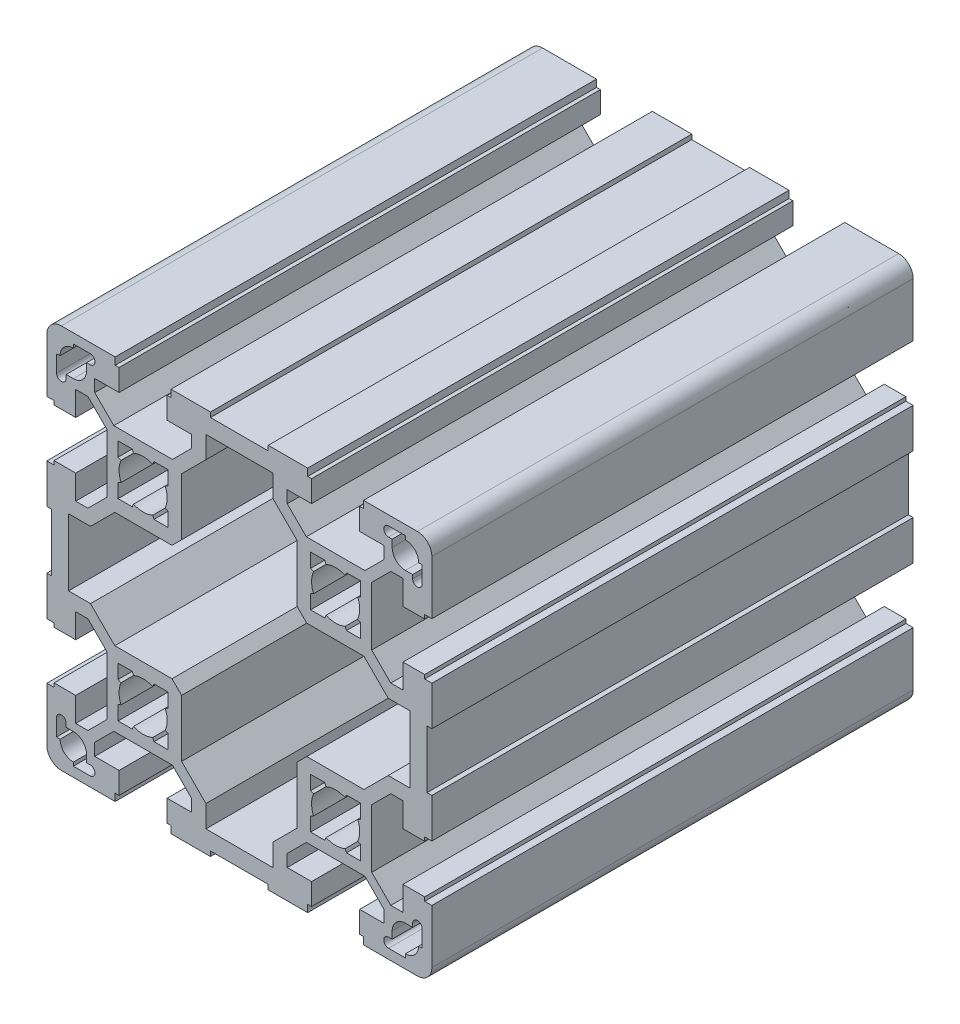
from build123d import *

# Parameters (mm, degrees)
BASE_EXTRUDE_DEPTH = 100


with BuildPart() as part:
    # Sketch2 → Base-Extrude (new body)
    with BuildSketch(Plane.XY):
        with BuildLine():
            Line((6, 40), (6, 39))
            Line((6, 39), (-6, 39))
            Line((-6, 39), (-6, 40))
            Line((-6, 40), (-14.2, 40))
            Line((-14.2, 40), (-14.2, 38.5))
            Line((-14.2, 38.5), (-15, 38.5))
            Line((-15, 38.5), (-15, 34))
            Line((-15, 34), (-9.95, 34))
            Line((-9.95, 34), (-9.95, 31.464213562))
            Line((-9.95, 31.464213562), (-13.914213562, 27.5))
            Line((-13.914213562, 27.5), (-26.085786438, 27.5))
            Line((-26.085786438, 27.5), (-30.05, 31.464213562))
            Line((-30.05, 31.464213562), (-30.05, 34))
            Line((-30.05, 34), (-25, 34))
            Line((-25, 34), (-25, 38.5))
            Line((-25, 38.5), (-25.8, 38.5))
            Line((-25.8, 38.5), (-25.8, 40))
            Line((-25.8, 40), (-37, 40))
            ThreePointArc((-37, 40), (-39.121320344, 39.121320344), (-40, 37))
            Line((-40, 37), (-40, 25.8))
            Line((-40, 25.8), (-38.5, 25.8))
            Line((-38.5, 25.8), (-38.5, 25))
            Line((-38.5, 25), (-34, 25))
            Line((-34, 25), (-34, 30.05))
            Line((-34, 30.05), (-31.464213562, 30.05))
            Line((-31.464213562, 30.05), (-27.5, 26.085786438))
            Line((-27.5, 26.085786438), (-27.5, 13.914213562))
            Line((-27.5, 13.914213562), (-31.464213562, 9.95))
            Line((-31.464213562, 9.95), (-34, 9.95))
            Line((-34, 9.95), (-34, 15))
            Line((-34, 15), (-38.5, 15))
            Line((-38.5, 15), (-38.5, 14.2))
            Line((-38.5, 14.2), (-40, 14.2))
            Line((-40, 14.2), (-40, 6))
            Line((-40, 6), (-39, 6))
            Line((-39, 6), (-39, -6))
            Line((-39, -6), (-40, -6))
            Line((-40, -6), (-40, -14.2))
            Line((-40, -14.2), (-38.5, -14.2))
            Line((-38.5, -14.2), (-38.5, -15))
            Line((-38.5, -15), (-34, -15))
            Line((-34, -15), (-34, -9.95))
            Line((-34, -9.95), (-31.464213562, -9.95))
            Line((-31.464213562, -9.95), (-27.5, -13.914213562))
            Line((-27.5, -13.914213562), (-27.5, -26.085786438))
            Line((-27.5, -26.085786438), (-31.464213562, -30.05))
            Line((-31.464213562, -30.05), (-34, -30.05))
            Line((-34, -30.05), (-34, -25))
            Line((-34, -25), (-38.5, -25))
            Line((-38.5, -25), (-38.5, -25.8))
            Line((-38.5, -25.8), (-40, -25.8))
            Line((-40, -25.8), (-40, -37))
            ThreePointArc((-40, -37), (-39.121320344, -39.121320344), (-37, -40))
            Line((-37, -40), (-25.8, -40))
            Line((-25.8, -40), (-25.8, -38.5))
            Line((-25.8, -38.5), (-25, -38.5))
            Line((-25, -38.5), (-25, -34))
            Line((-25, -34), (-30.05, -34))
            Line((-30.05, -34), (-30.05, -31.464213562))
            Line((-30.05, -31.464213562), (-26.085786438, -27.5))
            Line((-26.085786438, -27.5), (-13.914213562, -27.5))
            Line((-13.914213562, -27.5), (-9.95, -31.464213562))
            Line((-9.95, -31.464213562), (-9.95, -34))
            Line((-9.95, -34), (-15, -34))
            Line((-15, -34), (-15, -38.5))
            Line((-15, -38.5), (-14.2, -38.5))
            Line((-14.2, -38.5), (-14.2, -40))
            Line((-14.2, -40), (-6, -40))
            Line((-6, -40), (-6, -39))
            Line((-6, -39), (6, -39))
            Line((6, -39), (6, -40))
            Line((6, -40), (14.2, -40))
            Line((14.2, -40), (14.2, -38.5))
            Line((14.2, -38.5), (15, -38.5))
            Line((15, -38.5), (15, -34))
            Line((15, -34), (9.95, -34))
            Line((9.95, -34), (9.95, -31.464213562))
            Line((9.95, -31.464213562), (13.914213562, -27.5))
            Line((13.914213562, -27.5), (26.085786438, -27.5))
            Line((26.085786438, -27.5), (30.05, -31.464213562))
            Line((30.05, -31.464213562), (30.05, -34))
            Line((30.05, -34), (25, -34))
            Line((25, -34), (25, -38.5))
            Line((25, -38.5), (25.8, -38.5))
            Line((25.8, -38.5), (25.8, -40))
            Line((25.8, -40), (37, -40))
            ThreePointArc((37, -40), (39.121320344, -39.121320344), (40, -37))
            Line((40, -37), (40, -25.8))
            Line((40, -25.8), (38.5, -25.8))
            Line((38.5, -25.8), (38.5, -25))
            Line((38.5, -25), (34, -25))
            Line((34, -25), (34, -30.05))
            Line((34, -30.05), (31.464213562, -30.05))
            Line((31.464213562, -30.05), (27.5, -26.085786438))
            Line((27.5, -26.085786438), (27.5, -13.914213562))
            Line((27.5, -13.914213562), (31.464213562, -9.95))
            Line((31.464213562, -9.95), (34, -9.95))
            Line((34, -9.95), (34, -15))
            Line((34, -15), (38.5, -15))
            Line((38.5, -15), (38.5, -14.2))
            Line((38.5, -14.2), (40, -14.2))
            Line((40, -14.2), (40, -6))
            Line((40, -6), (39, -6))
            Line((39, -6), (39, 6))
            Line((39, 6), (40, 6))
            Line((40, 6), (40, 14.2))
            Line((40, 14.2), (38.5, 14.2))
            Line((38.5, 14.2), (38.5, 15))
            Line((38.5, 15), (34, 15))
            Line((34, 15), (34, 9.95))
            Line((34, 9.95), (31.464213562, 9.95))
            Line((31.464213562, 9.95), (27.5, 13.914213562))
            Line((27.5, 13.914213562), (27.5, 26.085786438))
            Line((27.5, 26.085786438), (31.464213562, 30.05))
            Line((31.464213562, 30.05), (34, 30.05))
            Line((34, 30.05), (34, 25))
            Line((34, 25), (38.5, 25))
            Line((38.5, 25), (38.5, 25.8))
            Line((38.5, 25.8), (40, 25.8))
            Line((40, 25.8), (40, 37))
            ThreePointArc((40, 37), (39.121320344, 39.121320344), (37, 40))
            Line((37, 40), (25.8, 40))
            Line((25.8, 40), (25.8, 38.5))
            Line((25.8, 38.5), (25, 38.5))
            Line((25, 38.5), (25, 34))
            Line((25, 34), (30.05, 34))
            Line((30.05, 34), (30.05, 31.464213562))
            Line((30.05, 31.464213562), (26.085786438, 27.5))
            Line((26.085786438, 27.5), (13.914213562, 27.5))
            Line((13.914213562, 27.5), (9.95, 31.464213562))
            Line((9.95, 31.464213562), (9.95, 34))
            Line((9.95, 34), (15, 34))
            Line((15, 34), (15, 38.5))
            Line((15, 38.5), (14.2, 38.5))
            Line((14.2, 38.5), (14.2, 40))
            Line((14.2, 40), (6, 40))
        make_face()
        with BuildLine():
            Line((25.2, 17.73897565), (24.585300372, 18.006254655))
            ThreePointArc((24.585300372, 18.006254655), (25, 20), (24.585300372, 21.993745345))
            Line((24.585300372, 21.993745345), (25.2, 22.26102435))
            Line((25.2, 22.26102435), (25.2, 25.2))
            Line((25.2, 25.2), (22.26102435, 25.2))
            Line((22.26102435, 25.2), (21.993745345, 24.585300372))
            ThreePointArc((21.993745345, 24.585300372), (20, 25), (18.006254655, 24.585300372))
            Line((18.006254655, 24.585300372), (17.73897565, 25.2))
            Line((17.73897565, 25.2), (14.8, 25.2))
            Line((14.8, 25.2), (14.8, 22.26102435))
            Line((14.8, 22.26102435), (15.414699628, 21.993745345))
            ThreePointArc((15.414699628, 21.993745345), (15, 20), (15.414699628, 18.006254655))
            Line((15.414699628, 18.006254655), (14.8, 17.73897565))
            Line((14.8, 17.73897565), (14.8, 14.8))
            Line((14.8, 14.8), (17.73897565, 14.8))
            Line((17.73897565, 14.8), (18.006254655, 15.414699628))
            ThreePointArc((18.006254655, 15.414699628), (20, 15), (21.993745345, 15.414699628))
            Line((21.993745345, 15.414699628), (22.26102435, 14.8))
            Line((22.26102435, 14.8), (25.2, 14.8))
            Line((25.2, 14.8), (25.2, 17.73897565))
        make_face(mode=Mode.SUBTRACT)
        with BuildLine():
            Line((38, 34.5), (37.25, 34.5))
            ThreePointArc((37.25, 34.5), (36.444543648, 36.444543648), (34.5, 37.25))
            Line((34.5, 37.25), (34.5, 38))
            Line((34.5, 38), (31, 38))
            ThreePointArc((31, 38), (30, 37), (31, 36))
            Line((31, 36), (31.75, 36))
            Line((31.75, 36), (31.75, 34.5))
            ThreePointArc((31.75, 34.5), (32.555456352, 32.555456352), (34.5, 31.75))
            Line((34.5, 31.75), (36, 31.75))
            Line((36, 31.75), (36, 31))
            ThreePointArc((36, 31), (37, 30), (38, 31))
            Line((38, 31), (38, 34.5))
        make_face(mode=Mode.SUBTRACT)
        Polygon((35.5, -6.95), (35.5, 6.95), (30.928679656, 6.95), (25.878679656, 12), (14, 12), (12, 14), (12, 25.878679656), (6.95, 30.928679656), (6.95, 35.5), (-6.95, 35.5), (-6.95, 30.928679656), (-12, 25.878679656), (-12, 14), (-14, 12), (-25.878679656, 12), (-30.928679656, 6.95), (-35.5, 6.95), (-35.5, -6.95), (-30.928679656, -6.95), (-25.878679656, -12), (-14, -12), (-12, -14), (-12, -25.878679656), (-6.95, -30.928679656), (-6.95, -35.5), (6.95, -35.5), (6.95, -30.928679656), (12, -25.878679656), (12, -14), (14, -12), (25.878679656, -12), (30.928679656, -6.95), align=None, mode=Mode.SUBTRACT)
        with BuildLine():
            Line((-25.2, 14.8), (-25.2, 17.73897565))
            Line((-25.2, 17.73897565), (-24.585300372, 18.006254655))
            ThreePointArc((-24.585300372, 18.006254655), (-25, 20), (-24.585300372, 21.993745345))
            Line((-24.585300372, 21.993745345), (-25.2, 22.26102435))
            Line((-25.2, 22.26102435), (-25.2, 25.2))
            Line((-25.2, 25.2), (-22.26102435, 25.2))
            Line((-22.26102435, 25.2), (-21.993745345, 24.585300372))
            ThreePointArc((-21.993745345, 24.585300372), (-20, 25), (-18.006254655, 24.585300372))
            Line((-18.006254655, 24.585300372), (-17.73897565, 25.2))
            Line((-17.73897565, 25.2), (-14.8, 25.2))
            Line((-14.8, 25.2), (-14.8, 22.26102435))
            Line((-14.8, 22.26102435), (-15.414699628, 21.993745345))
            ThreePointArc((-15.414699628, 21.993745345), (-15, 20), (-15.414699628, 18.006254655))
            Line((-15.414699628, 18.006254655), (-14.8, 17.73897565))
            Line((-14.8, 17.73897565), (-14.8, 14.8))
            Line((-14.8, 14.8), (-17.73897565, 14.8))
            Line((-17.73897565, 14.8), (-18.006254655, 15.414699628))
            ThreePointArc((-18.006254655, 15.414699628), (-20, 15), (-21.993745345, 15.414699628))
            Line((-21.993745345, 15.414699628), (-22.26102435, 14.8))
            Line((-22.26102435, 14.8), (-25.2, 14.8))
        make_face(mode=Mode.SUBTRACT)
        with BuildLine():
            Line((-38, 31), (-38, 34.5))
            Line((-38, 34.5), (-37.25, 34.5))
            ThreePointArc((-37.25, 34.5), (-36.444543648, 36.444543648), (-34.5, 37.25))
            Line((-34.5, 37.25), (-34.5, 38))
            Line((-34.5, 38), (-31, 38))
            ThreePointArc((-31, 38), (-30, 37), (-31, 36))
            Line((-31, 36), (-31.75, 36))
            Line((-31.75, 36), (-31.75, 34.5))
            ThreePointArc((-31.75, 34.5), (-32.555456352, 32.555456352), (-34.5, 31.75))
            Line((-34.5, 31.75), (-36, 31.75))
            Line((-36, 31.75), (-36, 31))
            ThreePointArc((-36, 31), (-37, 30), (-38, 31))
        make_face(mode=Mode.SUBTRACT)
        with BuildLine():
            Line((-25.2, -17.73897565), (-24.585300372, -18.006254655))
            ThreePointArc((-24.585300372, -18.006254655), (-25, -20), (-24.585300372, -21.993745345))
            Line((-24.585300372, -21.993745345), (-25.2, -22.26102435))
            Line((-25.2, -22.26102435), (-25.2, -25.2))
            Line((-25.2, -25.2), (-22.26102435, -25.2))
            Line((-22.26102435, -25.2), (-21.993745345, -24.585300372))
            ThreePointArc((-21.993745345, -24.585300372), (-20, -25), (-18.006254655, -24.585300372))
            Line((-18.006254655, -24.585300372), (-17.73897565, -25.2))
            Line((-17.73897565, -25.2), (-14.8, -25.2))
            Line((-14.8, -25.2), (-14.8, -22.26102435))
            Line((-14.8, -22.26102435), (-15.414699628, -21.993745345))
            ThreePointArc((-15.414699628, -21.993745345), (-15, -20), (-15.414699628, -18.006254655))
            Line((-15.414699628, -18.006254655), (-14.8, -17.73897565))
            Line((-14.8, -17.73897565), (-14.8, -14.8))
            Line((-14.8, -14.8), (-17.73897565, -14.8))
            Line((-17.73897565, -14.8), (-18.006254655, -15.414699628))
            ThreePointArc((-18.006254655, -15.414699628), (-20, -15), (-21.993745345, -15.414699628))
            Line((-21.993745345, -15.414699628), (-22.26102435, -14.8))
            Line((-22.26102435, -14.8), (-25.2, -14.8))
            Line((-25.2, -14.8), (-25.2, -17.73897565))
        make_face(mode=Mode.SUBTRACT)
        with BuildLine():
            Line((-38, -34.5), (-37.25, -34.5))
            ThreePointArc((-37.25, -34.5), (-36.444543648, -36.444543648), (-34.5, -37.25))
            Line((-34.5, -37.25), (-34.5, -38))
            Line((-34.5, -38), (-31, -38))
            ThreePointArc((-31, -38), (-30, -37), (-31, -36))
            Line((-31, -36), (-31.75, -36))
            Line((-31.75, -36), (-31.75, -34.5))
            ThreePointArc((-31.75, -34.5), (-32.555456352, -32.555456352), (-34.5, -31.75))
            Line((-34.5, -31.75), (-36, -31.75))
            Line((-36, -31.75), (-36, -31))
            ThreePointArc((-36, -31), (-37, -30), (-38, -31))
            Line((-38, -31), (-38, -34.5))
        make_face(mode=Mode.SUBTRACT)
        with BuildLine():
            Line((25.2, -14.8), (25.2, -17.73897565))
            Line((25.2, -17.73897565), (24.585300372, -18.006254655))
            ThreePointArc((24.585300372, -18.006254655), (25, -20), (24.585300372, -21.993745345))
            Line((24.585300372, -21.993745345), (25.2, -22.26102435))
            Line((25.2, -22.26102435), (25.2, -25.2))
            Line((25.2, -25.2), (22.26102435, -25.2))
            Line((22.26102435, -25.2), (21.993745345, -24.585300372))
            ThreePointArc((21.993745345, -24.585300372), (20, -25), (18.006254655, -24.585300372))
            Line((18.006254655, -24.585300372), (17.73897565, -25.2))
            Line((17.73897565, -25.2), (14.8, -25.2))
            Line((14.8, -25.2), (14.8, -22.26102435))
            Line((14.8, -22.26102435), (15.414699628, -21.993745345))
            ThreePointArc((15.414699628, -21.993745345), (15, -20), (15.414699628, -18.006254655))
            Line((15.414699628, -18.006254655), (14.8, -17.73897565))
            Line((14.8, -17.73897565), (14.8, -14.8))
            Line((14.8, -14.8), (17.73897565, -14.8))
            Line((17.73897565, -14.8), (18.006254655, -15.414699628))
            ThreePointArc((18.006254655, -15.414699628), (20, -15), (21.993745345, -15.414699628))
            Line((21.993745345, -15.414699628), (22.26102435, -14.8))
            Line((22.26102435, -14.8), (25.2, -14.8))
        make_face(mode=Mode.SUBTRACT)
        with BuildLine():
            Line((38, -31), (38, -34.5))
            Line((38, -34.5), (37.25, -34.5))
            ThreePointArc((37.25, -34.5), (36.444543648, -36.444543648), (34.5, -37.25))
            Line((34.5, -37.25), (34.5, -38))
            Line((34.5, -38), (31, -38))
            ThreePointArc((31, -38), (30, -37), (31, -36))
            Line((31, -36), (31.75, -36))
            Line((31.75, -36), (31.75, -34.5))
            ThreePointArc((31.75, -34.5), (32.555456352, -32.555456352), (34.5, -31.75))
            Line((34.5, -31.75), (36, -31.75))
            Line((36, -31.75), (36, -31))
            ThreePointArc((36, -31), (37, -30), (38, -31))
        make_face(mode=Mode.SUBTRACT)
    extrude(amount=-BASE_EXTRUDE_DEPTH)


solid = part.part
